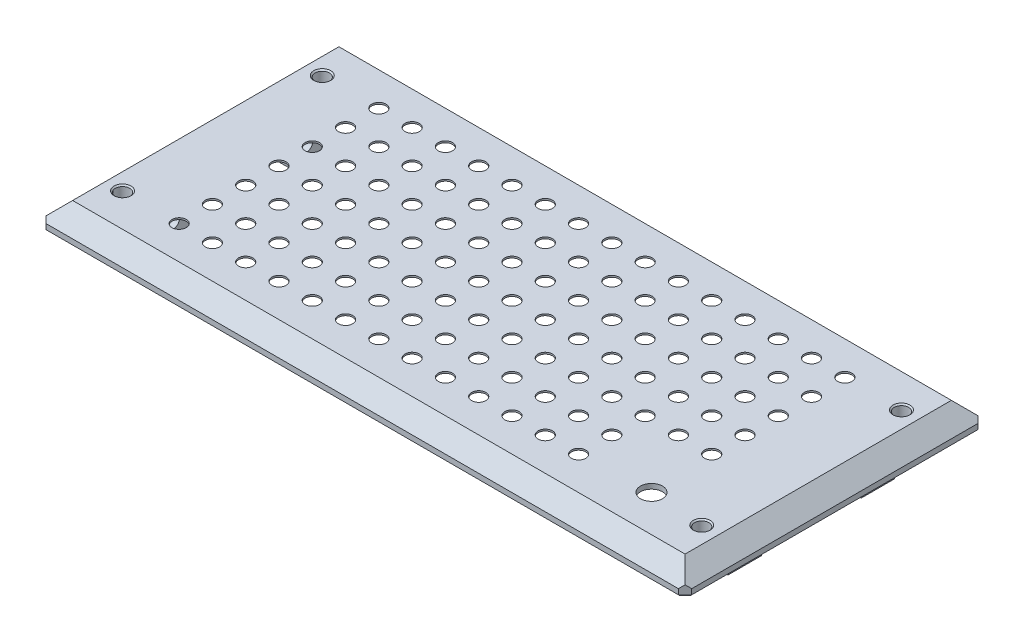
from build123d import *

# Parameters (mm, degrees)
SKETCH1_W           = 194
SKETCH1_H           = 90
BOSS_EXTRUDE1_DEPTH = 2
SKETCH3_W           = 184
SKETCH3_H           = 80
SKETCH2_W           = 194
SKETCH2_H           = 90
CHAMFER2_SIZE       = 2
SKETCH4_W           = 8
SKETCH4_H           = 10
BOSS_EXTRUDE2_DEPTH = 7
SKETCH5_R           = 2.05
CUT_EXTRUDE1_DEPTH  = 187.9000001
SKETCH6_W           = 161.8
SKETCH6_H           = 78
CUT_EXTRUDE2_DEPTH  = 5.5
SKETCH7_R           = 2.15
CUT_EXTRUDE3_DEPTH  = 2.5000001
SKETCH8_R           = 4.2
CUT_EXTRUDE4_DEPTH  = 1
SKETCH13_R          = 4.2
BOSS_EXTRUDE3_DEPTH = 1.5
SKETCH10_R          = 3.3
CUT_EXTRUDE5_DEPTH  = 2.5000001
SKETCH11_W          = 10
SKETCH11_H          = 20
CUT_EXTRUDE6_DEPTH  = 5.5
SKETCH12_R          = 2.15
CUT_EXTRUDE7_DEPTH  = 8.0000001
CHAMFER3_SIZE       = 0.4
CHAMFER4_SIZE       = 0.4
CHAMFER5_SIZE       = 0.4


with BuildPart() as part:
    # Sketch1 → Boss-Extrude1 (new body)
    with BuildSketch(Plane(origin=(0, 0, 0), x_dir=(1, 0, 0), z_dir=(0, 1, 0))):
        Rectangle(SKETCH1_W, SKETCH1_H)
    extrude(amount=BOSS_EXTRUDE1_DEPTH)

    # Sketch3 → Loft1 section 0
    with BuildSketch(Plane(origin=(0, 7, 0), x_dir=(1, 0, 0), z_dir=(0, 1, 0))):
        Rectangle(SKETCH3_W, SKETCH3_H)
    # Sketch2 → Loft1 section 1
    with BuildSketch(Plane(origin=(0, 2, 0), x_dir=(1, 0, 0), z_dir=(0, 1, 0))):
        Rectangle(SKETCH2_W, SKETCH2_H)
    loft()

    # Chamfer2
    chamfer2_edges = [part.edges().sort_by_distance(p)[0] for p in [
        (97, 1, 45),
        (-97, 1, 45),
        (-97, 1, -45),
        (97, 1, -45),
    ]]
    chamfer(chamfer2_edges, length=CHAMFER2_SIZE)

    # Sketch4 → Boss-Extrude2 (add)
    with BuildSketch(Plane.XZ):
        with Locations((-85.9, 20)):
            Rectangle(SKETCH4_W, SKETCH4_H)
        with Locations((-85.9, -20)):
            Rectangle(SKETCH4_W, SKETCH4_H)
        with Locations((85.9, -20)):
            Rectangle(SKETCH4_W, SKETCH4_H)
        with Locations((85.9, 20)):
            Rectangle(SKETCH4_W, SKETCH4_H)
    extrude(amount=BOSS_EXTRUDE2_DEPTH)

    # Sketch5 → Cut-Extrude1 (cut, through all)
    with BuildSketch(Plane.ZY.offset(89.9)):
        with Locations((-20, -3.5)):
            Circle(SKETCH5_R)
        with Locations((20, -3.5)):
            Circle(SKETCH5_R)
    extrude(amount=-CUT_EXTRUDE1_DEPTH, mode=Mode.SUBTRACT)

    # Sketch6 → Cut-Extrude2 (cut)
    with BuildSketch(Plane.XZ):
        Rectangle(SKETCH6_W, SKETCH6_H)
    extrude(amount=-CUT_EXTRUDE2_DEPTH, mode=Mode.SUBTRACT)

    # Sketch7 → Cut-Extrude3 (cut, through all)
    with BuildSketch(Plane.XZ.offset(-5.5)):
        Circle(SKETCH7_R)
        with Locations((10, 0)):
            Circle(SKETCH7_R)
        with Locations((20, 0)):
            Circle(SKETCH7_R)
        with Locations((30, 0)):
            Circle(SKETCH7_R)
        with Locations((40, 0)):
            Circle(SKETCH7_R)
        with Locations((50, 0)):
            Circle(SKETCH7_R)
        with Locations((10, 10)):
            Circle(SKETCH7_R)
        with Locations((20, 10)):
            Circle(SKETCH7_R)
        with Locations((30, 10)):
            Circle(SKETCH7_R)
        with Locations((40, 10)):
            Circle(SKETCH7_R)
        with Locations((50, 10)):
            Circle(SKETCH7_R)
        with Locations((10, 20)):
            Circle(SKETCH7_R)
        with Locations((20, 20)):
            Circle(SKETCH7_R)
        with Locations((30, 20)):
            Circle(SKETCH7_R)
        with Locations((40, 20)):
            Circle(SKETCH7_R)
        with Locations((50, 20)):
            Circle(SKETCH7_R)
        with Locations((10, 30)):
            Circle(SKETCH7_R)
        with Locations((20, 30)):
            Circle(SKETCH7_R)
        with Locations((30, 30)):
            Circle(SKETCH7_R)
        with Locations((40, 30)):
            Circle(SKETCH7_R)
        with Locations((50, 30)):
            Circle(SKETCH7_R)
        with Locations((0, 10)):
            Circle(SKETCH7_R)
        with Locations((0, 20)):
            Circle(SKETCH7_R)
        with Locations((0, 30)):
            Circle(SKETCH7_R)
        with Locations((-50, 30)):
            Circle(SKETCH7_R)
        with Locations((-40, 30)):
            Circle(SKETCH7_R)
        with Locations((-30, 30)):
            Circle(SKETCH7_R)
        with Locations((-20, 30)):
            Circle(SKETCH7_R)
        with Locations((-10, 30)):
            Circle(SKETCH7_R)
        with Locations((-50, 20)):
            Circle(SKETCH7_R)
        with Locations((-40, 20)):
            Circle(SKETCH7_R)
        with Locations((-30, 20)):
            Circle(SKETCH7_R)
        with Locations((-20, 20)):
            Circle(SKETCH7_R)
        with Locations((-10, 20)):
            Circle(SKETCH7_R)
        with Locations((-50, 10)):
            Circle(SKETCH7_R)
        with Locations((-40, 10)):
            Circle(SKETCH7_R)
        with Locations((-30, 10)):
            Circle(SKETCH7_R)
        with Locations((-20, 10)):
            Circle(SKETCH7_R)
        with Locations((-10, 10)):
            Circle(SKETCH7_R)
        with Locations((-50, 0)):
            Circle(SKETCH7_R)
        with Locations((-40, 0)):
            Circle(SKETCH7_R)
        with Locations((-30, 0)):
            Circle(SKETCH7_R)
        with Locations((-20, 0)):
            Circle(SKETCH7_R)
        with Locations((-10, 0)):
            Circle(SKETCH7_R)
        with Locations((-10, -10)):
            Circle(SKETCH7_R)
        with Locations((-20, -10)):
            Circle(SKETCH7_R)
        with Locations((-30, -10)):
            Circle(SKETCH7_R)
        with Locations((-40, -10)):
            Circle(SKETCH7_R)
        with Locations((-50, -10)):
            Circle(SKETCH7_R)
        with Locations((-10, -20)):
            Circle(SKETCH7_R)
        with Locations((-20, -20)):
            Circle(SKETCH7_R)
        with Locations((-30, -20)):
            Circle(SKETCH7_R)
        with Locations((-40, -20)):
            Circle(SKETCH7_R)
        with Locations((-50, -20)):
            Circle(SKETCH7_R)
        with Locations((-10, -30)):
            Circle(SKETCH7_R)
        with Locations((-20, -30)):
            Circle(SKETCH7_R)
        with Locations((-30, -30)):
            Circle(SKETCH7_R)
        with Locations((-40, -30)):
            Circle(SKETCH7_R)
        with Locations((-50, -30)):
            Circle(SKETCH7_R)
        with Locations((0, -30)):
            Circle(SKETCH7_R)
        with Locations((0, -20)):
            Circle(SKETCH7_R)
        with Locations((0, -10)):
            Circle(SKETCH7_R)
        with Locations((50, -30)):
            Circle(SKETCH7_R)
        with Locations((40, -30)):
            Circle(SKETCH7_R)
        with Locations((30, -30)):
            Circle(SKETCH7_R)
        with Locations((20, -30)):
            Circle(SKETCH7_R)
        with Locations((10, -30)):
            Circle(SKETCH7_R)
        with Locations((50, -20)):
            Circle(SKETCH7_R)
        with Locations((40, -20)):
            Circle(SKETCH7_R)
        with Locations((30, -20)):
            Circle(SKETCH7_R)
        with Locations((20, -20)):
            Circle(SKETCH7_R)
        with Locations((10, -20)):
            Circle(SKETCH7_R)
        with Locations((50, -10)):
            Circle(SKETCH7_R)
        with Locations((40, -10)):
            Circle(SKETCH7_R)
        with Locations((30, -10)):
            Circle(SKETCH7_R)
        with Locations((20, -10)):
            Circle(SKETCH7_R)
        with Locations((10, -10)):
            Circle(SKETCH7_R)
        with Locations((60, 0)):
            Circle(SKETCH7_R)
        with Locations((70, 0)):
            Circle(SKETCH7_R)
        with Locations((60, 10)):
            Circle(SKETCH7_R)
        with Locations((70, 10)):
            Circle(SKETCH7_R)
        with Locations((60, 20)):
            Circle(SKETCH7_R)
        with Locations((70, 20)):
            Circle(SKETCH7_R)
        with Locations((60, 30)):
            Circle(SKETCH7_R)
        with Locations((70, 30)):
            Circle(SKETCH7_R)
        with Locations((70, -30)):
            Circle(SKETCH7_R)
        with Locations((60, -30)):
            Circle(SKETCH7_R)
        with Locations((70, -20)):
            Circle(SKETCH7_R)
        with Locations((60, -20)):
            Circle(SKETCH7_R)
        with Locations((70, -10)):
            Circle(SKETCH7_R)
        with Locations((60, -10)):
            Circle(SKETCH7_R)
        with Locations((-60, -10)):
            Circle(SKETCH7_R)
        with Locations((-70, -10)):
            Circle(SKETCH7_R)
        with Locations((-60, -20)):
            Circle(SKETCH7_R)
        with Locations((-70, -20)):
            Circle(SKETCH7_R)
        with Locations((-60, -30)):
            Circle(SKETCH7_R)
        with Locations((-70, -30)):
            Circle(SKETCH7_R)
        with Locations((-70, 30)):
            Circle(SKETCH7_R)
        with Locations((-60, 30)):
            Circle(SKETCH7_R)
        with Locations((-70, 20)):
            Circle(SKETCH7_R)
        with Locations((-60, 20)):
            Circle(SKETCH7_R)
        with Locations((-70, 10)):
            Circle(SKETCH7_R)
        with Locations((-60, 10)):
            Circle(SKETCH7_R)
        with Locations((-70, 0)):
            Circle(SKETCH7_R)
        with Locations((-60, 0)):
            Circle(SKETCH7_R)
    extrude(amount=-CUT_EXTRUDE3_DEPTH, mode=Mode.SUBTRACT)

    # Sketch8 → Cut-Extrude4 (cut)
    with BuildSketch(Plane.XZ.offset(-5.5)):
        Circle(SKETCH8_R)
        with Locations((10, 0)):
            Circle(SKETCH8_R)
        with Locations((20, 0)):
            Circle(SKETCH8_R)
        with Locations((30, 0)):
            Circle(SKETCH8_R)
        with Locations((40, 0)):
            Circle(SKETCH8_R)
        with Locations((50, 0)):
            Circle(SKETCH8_R)
        with Locations((10, 10)):
            Circle(SKETCH8_R)
        with Locations((20, 10)):
            Circle(SKETCH8_R)
        with Locations((30, 10)):
            Circle(SKETCH8_R)
        with Locations((40, 10)):
            Circle(SKETCH8_R)
        with Locations((50, 10)):
            Circle(SKETCH8_R)
        with Locations((10, 20)):
            Circle(SKETCH8_R)
        with Locations((20, 20)):
            Circle(SKETCH8_R)
        with Locations((30, 20)):
            Circle(SKETCH8_R)
        with Locations((40, 20)):
            Circle(SKETCH8_R)
        with Locations((50, 20)):
            Circle(SKETCH8_R)
        with Locations((10, 30)):
            Circle(SKETCH8_R)
        with Locations((20, 30)):
            Circle(SKETCH8_R)
        with Locations((30, 30)):
            Circle(SKETCH8_R)
        with Locations((40, 30)):
            Circle(SKETCH8_R)
        with Locations((50, 30)):
            Circle(SKETCH8_R)
        with Locations((0, 10)):
            Circle(SKETCH8_R)
        with Locations((0, 20)):
            Circle(SKETCH8_R)
        with Locations((0, 30)):
            Circle(SKETCH8_R)
        with Locations((0, -30)):
            Circle(SKETCH8_R)
        with Locations((0, -20)):
            Circle(SKETCH8_R)
        with Locations((0, -10)):
            Circle(SKETCH8_R)
        with Locations((50, -30)):
            Circle(SKETCH8_R)
        with Locations((40, -30)):
            Circle(SKETCH8_R)
        with Locations((30, -30)):
            Circle(SKETCH8_R)
        with Locations((20, -30)):
            Circle(SKETCH8_R)
        with Locations((10, -30)):
            Circle(SKETCH8_R)
        with Locations((50, -20)):
            Circle(SKETCH8_R)
        with Locations((40, -20)):
            Circle(SKETCH8_R)
        with Locations((30, -20)):
            Circle(SKETCH8_R)
        with Locations((20, -20)):
            Circle(SKETCH8_R)
        with Locations((10, -20)):
            Circle(SKETCH8_R)
        with Locations((50, -10)):
            Circle(SKETCH8_R)
        with Locations((40, -10)):
            Circle(SKETCH8_R)
        with Locations((30, -10)):
            Circle(SKETCH8_R)
        with Locations((20, -10)):
            Circle(SKETCH8_R)
        with Locations((10, -10)):
            Circle(SKETCH8_R)
        with Locations((-10, -10)):
            Circle(SKETCH8_R)
        with Locations((-20, -10)):
            Circle(SKETCH8_R)
        with Locations((-30, -10)):
            Circle(SKETCH8_R)
        with Locations((-40, -10)):
            Circle(SKETCH8_R)
        with Locations((-50, -10)):
            Circle(SKETCH8_R)
        with Locations((-10, -20)):
            Circle(SKETCH8_R)
        with Locations((-20, -20)):
            Circle(SKETCH8_R)
        with Locations((-30, -20)):
            Circle(SKETCH8_R)
        with Locations((-40, -20)):
            Circle(SKETCH8_R)
        with Locations((-50, -20)):
            Circle(SKETCH8_R)
        with Locations((-10, -30)):
            Circle(SKETCH8_R)
        with Locations((-20, -30)):
            Circle(SKETCH8_R)
        with Locations((-30, -30)):
            Circle(SKETCH8_R)
        with Locations((-40, -30)):
            Circle(SKETCH8_R)
        with Locations((-50, -30)):
            Circle(SKETCH8_R)
        with Locations((-50, 30)):
            Circle(SKETCH8_R)
        with Locations((-40, 30)):
            Circle(SKETCH8_R)
        with Locations((-30, 30)):
            Circle(SKETCH8_R)
        with Locations((-20, 30)):
            Circle(SKETCH8_R)
        with Locations((-10, 30)):
            Circle(SKETCH8_R)
        with Locations((-50, 20)):
            Circle(SKETCH8_R)
        with Locations((-40, 20)):
            Circle(SKETCH8_R)
        with Locations((-30, 20)):
            Circle(SKETCH8_R)
        with Locations((-20, 20)):
            Circle(SKETCH8_R)
        with Locations((-10, 20)):
            Circle(SKETCH8_R)
        with Locations((-50, 10)):
            Circle(SKETCH8_R)
        with Locations((-40, 10)):
            Circle(SKETCH8_R)
        with Locations((-30, 10)):
            Circle(SKETCH8_R)
        with Locations((-20, 10)):
            Circle(SKETCH8_R)
        with Locations((-10, 10)):
            Circle(SKETCH8_R)
        with Locations((-50, 0)):
            Circle(SKETCH8_R)
        with Locations((-40, 0)):
            Circle(SKETCH8_R)
        with Locations((-30, 0)):
            Circle(SKETCH8_R)
        with Locations((-20, 0)):
            Circle(SKETCH8_R)
        with Locations((-10, 0)):
            Circle(SKETCH8_R)
        with Locations((60, 0)):
            Circle(SKETCH8_R)
        with Locations((70, 0)):
            Circle(SKETCH8_R)
        with Locations((60, 10)):
            Circle(SKETCH8_R)
        with Locations((70, 10)):
            Circle(SKETCH8_R)
        with Locations((60, 20)):
            Circle(SKETCH8_R)
        with Locations((70, 20)):
            Circle(SKETCH8_R)
        with Locations((60, 30)):
            Circle(SKETCH8_R)
        with Locations((70, 30)):
            Circle(SKETCH8_R)
        with Locations((70, -30)):
            Circle(SKETCH8_R)
        with Locations((60, -30)):
            Circle(SKETCH8_R)
        with Locations((70, -20)):
            Circle(SKETCH8_R)
        with Locations((60, -20)):
            Circle(SKETCH8_R)
        with Locations((70, -10)):
            Circle(SKETCH8_R)
        with Locations((60, -10)):
            Circle(SKETCH8_R)
        with Locations((-60, -10)):
            Circle(SKETCH8_R)
        with Locations((-60, -20)):
            Circle(SKETCH8_R)
        with Locations((-60, -30)):
            Circle(SKETCH8_R)
        with Locations((-60, 0)):
            Circle(SKETCH8_R)
        with Locations((-70, -10)):
            Circle(SKETCH8_R)
        with Locations((-70, -20)):
            Circle(SKETCH8_R)
        with Locations((-70, -30)):
            Circle(SKETCH8_R)
        with Locations((-70, 30)):
            Circle(SKETCH8_R)
        with Locations((-60, 30)):
            Circle(SKETCH8_R)
        with Locations((-70, 20)):
            Circle(SKETCH8_R)
        with Locations((-60, 20)):
            Circle(SKETCH8_R)
        with Locations((-70, 10)):
            Circle(SKETCH8_R)
        with Locations((-60, 10)):
            Circle(SKETCH8_R)
        with Locations((-70, 0)):
            Circle(SKETCH8_R)
    extrude(amount=-CUT_EXTRUDE4_DEPTH, mode=Mode.SUBTRACT)

    # Sketch13 → Boss-Extrude3 (add)
    with BuildSketch(Plane.XZ.offset(-5.5)):
        with Locations((60, 20)):
            Circle(SKETCH13_R)
        with Locations((70, 20)):
            Circle(SKETCH13_R)
        with Locations((70, 30)):
            Circle(SKETCH13_R)
        with Locations((60, 30)):
            Circle(SKETCH13_R)
    extrude(amount=-BOSS_EXTRUDE3_DEPTH)

    # Sketch10 → Cut-Extrude5 (cut, through all)
    with BuildSketch(Plane.XZ.offset(-5.5)):
        with Locations((70.9, 29)):
            Circle(SKETCH10_R)
    extrude(amount=-CUT_EXTRUDE5_DEPTH, mode=Mode.SUBTRACT)

    # Sketch11 → Cut-Extrude6 (cut)
    with BuildSketch(Plane.XZ):
        with Locations((85.9, 0)):
            Rectangle(SKETCH11_W, SKETCH11_H)
        with Locations((-85.9, 0)):
            Rectangle(SKETCH11_W, SKETCH11_H)
    extrude(amount=-CUT_EXTRUDE6_DEPTH, mode=Mode.SUBTRACT)

    # Sketch12 → Cut-Extrude7 (cut, through all)
    with BuildSketch(Plane.XZ):
        with Locations((-87, 30)):
            Circle(SKETCH12_R)
        with Locations((-87, -30)):
            Circle(SKETCH12_R)
        with Locations((87, -30)):
            Circle(SKETCH12_R)
        with Locations((87, 30)):
            Circle(SKETCH12_R)
    extrude(amount=-CUT_EXTRUDE7_DEPTH, mode=Mode.SUBTRACT)

    # Chamfer3
    chamfer3_edges = [part.edges().sort_by_distance(p)[0] for p in [
        (0, 0, -45),
        (97, 0, 0),
        (0, 0, 45),
        (-97, 0, 0),
        (96, 0, 44),
        (-96, 0, 44),
        (-96, 0, -44),
        (96, 0, -44),
    ]]
    chamfer(chamfer3_edges, length=CHAMFER3_SIZE)

    # Chamfer4
    chamfer4_edges = [part.edges().sort_by_distance(p)[0] for p in [
        (84.85, 7, 30),
        (84.85, 7, -30),
        (-89.15, 7, -30),
        (-89.15, 7, 30),
    ]]
    chamfer(chamfer4_edges, length=CHAMFER4_SIZE)

    # Chamfer5
    chamfer5_edges = [part.edges().sort_by_distance(p)[0] for p in [
        (89.9, -3.5, -22.05),
        (-89.9, -3.5, -22.05),
        (89.9, -3.5, 17.95),
        (-89.9, -3.5, 17.95),
    ]]
    chamfer(chamfer5_edges, length=CHAMFER5_SIZE)


solid = part.part
